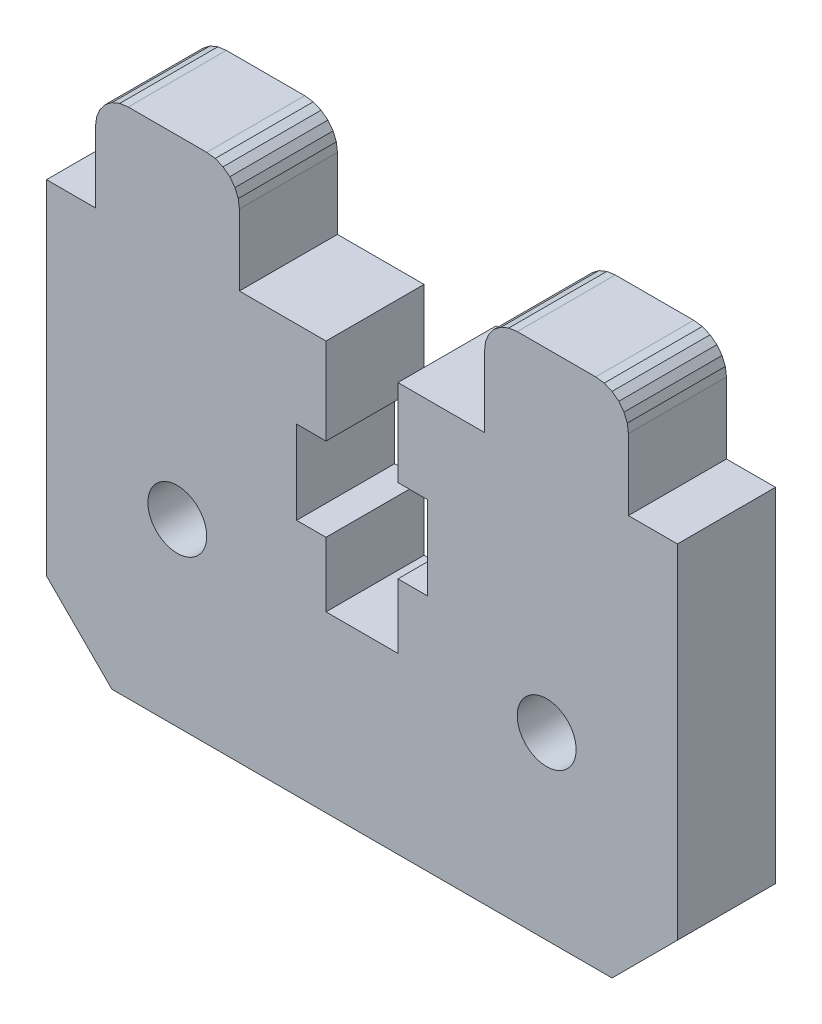
from build123d import *

# Parameters (mm, degrees)
MODEL_R                  = 1.8
RESSALTO_EXTRUS_O1_DEPTH = 6


with BuildPart() as part:
    # Model → Ressalto-extrusão1 (new body)
    with BuildSketch(Plane.XY):
        Polygon((53.041414253, 36.88413465), (53.455627815, 37.201971895), (53.937989725, 37.40177274), (54.455627815, 37.469921087), (59.255622257, 37.469921087), (59.773260347, 37.40177274), (60.255622257, 37.201971895), (60.66983582, 36.88413465), (60.987673065, 36.469921087), (61.18747391, 35.987559177), (61.255622257, 35.469921087), (61.255622257, 31.119923196), (64.255622257, 31.119923196), (64.255622257, 10.119923196), (60.255622257, 6.119923196), (29.655637917, 6.119923196), (25.655637917, 10.119923196), (25.655637917, 31.119923196), (28.655637917, 31.119923196), (28.655637917, 35.469921087), (28.723786264, 35.987559177), (28.923587109, 36.469921087), (29.241424354, 36.88413465), (29.655637917, 37.201971895), (30.137999826, 37.40177274), (30.655637917, 37.469921087), (35.455633882, 37.469921087), (35.973271972, 37.40177274), (36.455633882, 37.201971895), (36.869847444, 36.88413465), (37.187684689, 36.469921087), (37.387485534, 35.987559177), (37.455633882, 35.469921087), (37.455633882, 31.119923196), (42.755625888, 31.119923196), (42.755625888, 25.819924374), (40.955627657, 25.819924374), (40.955627657, 20.71992661), (42.755625888, 20.71992661), (42.755625888, 16.769926787), (47.15563056, 16.769926787), (47.15563056, 20.71992661), (48.955628792, 20.71992661), (48.955628792, 25.819924374), (47.15563056, 25.819924374), (47.15563056, 31.119923196), (52.455627815, 31.119923196), (52.455627815, 35.469921087), (52.523776162, 35.987559177), (52.723577008, 36.469921087), align=None)
        with Locations((56.255622257, 17.119923196)):
            Circle(MODEL_R, mode=Mode.SUBTRACT)
        with Locations((33.655637917, 17.119923196)):
            Circle(MODEL_R, mode=Mode.SUBTRACT)
    extrude(amount=RESSALTO_EXTRUS_O1_DEPTH)


solid = part.part
